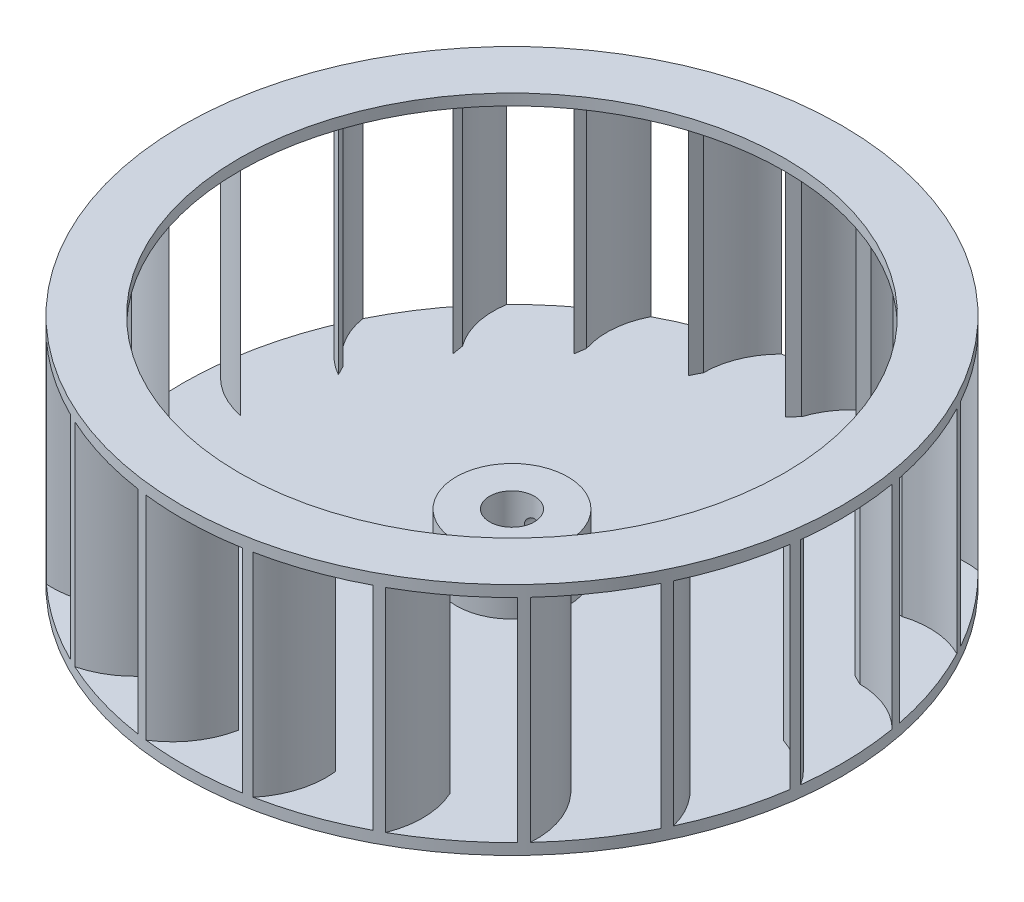
from build123d import *

# Parameters (mm, degrees)
SKETCH2_R           = 59
BOSS_EXTRUDE1_DEPTH = 2
BOSS_EXTRUDE2_DEPTH = 38
SKETCH4_R           = 59
SKETCH4_R_2         = 48.802353881
BOSS_EXTRUDE3_DEPTH = 2
SKETCH5_R           = 10
SKETCH5_R_2         = 4
BOSS_EXTRUDE4_DEPTH = 10
SKETCH6_R           = 1.5
CUT_EXTRUDE1_DEPTH  = 25
SKETCH7_R           = 4
CUT_EXTRUDE2_DEPTH  = 3


with BuildPart() as part:
    # Sketch2 → Boss-Extrude1 (new body)
    with BuildSketch(Plane(origin=(0, 0, 0), x_dir=(1, 0, 0), z_dir=(0, 1, 0))):
        Circle(SKETCH2_R)
    extrude(amount=BOSS_EXTRUDE1_DEPTH)

    # Sketch3 → Boss-Extrude2 (add)
    with BuildSketch(Plane(origin=(0, 2, 0), x_dir=(1, 0, 0), z_dir=(0, 1, 0))):
        with BuildLine():
            Line((-14.892857143, 46.474428995), (-14, 48.26406754))
            ThreePointArc((-14, 48.26406754), (-12.934313455, 53.621635593), (-9.899494937, 58.163562477))
            ThreePointArc((-9.899494937, 58.163562477), (-10.714001991, 58.019049986), (-11.526402854, 57.863131934))
            ThreePointArc((-11.526402854, 57.863131934), (-14.384712835, 52.516130174), (-14.892857143, 46.474428995))
        make_face()
        with BuildLine():
            Line((0.197439531, 48.801954489), (1.599625859, 50.228093858))
            ThreePointArc((1.599625859, 50.228093858), (4.268733569, 54.994128614), (8.558550091, 58.375947276))
            ThreePointArc((8.558550091, 58.375947276), (7.739251034, 58.490204252), (6.918430571, 58.592963045))
            ThreePointArc((6.918430571, 58.592963045), (2.547701825, 54.390928538), (0.197439531, 48.801954489))
        make_face()
        with BuildLine():
            Line((15.268409449, 46.352404654), (17.042669195, 47.27544439))
            ThreePointArc((17.042669195, 47.27544439), (21.05392721, 50.983413159), (26.178824605, 52.874087626))
            ThreePointArc((26.178824605, 52.874087626), (25.434932246, 53.2359298), (24.686039809, 53.587306692))
            ThreePointArc((24.686039809, 53.587306692), (19.230729681, 50.941563853), (15.268409449, 46.352404654))
        make_face()
        with BuildLine():
            Line((28.844801068, 39.365558495), (30.817457326, 39.695145037))
            ThreePointArc((30.817457326, 39.695145037), (35.778215764, 41.982086001), (41.236533368, 42.196543884))
            ThreePointArc((41.236533368, 42.196543884), (40.640865073, 42.770551623), (40.037207473, 43.336151396))
            ThreePointArc((40.037207473, 43.336151396), (34.031319726, 42.505683967), (28.844801068, 39.365558495))
        make_face()
        with BuildLine():
            Line((39.597662585, 28.525337195), (41.575618016, 28.229208316))
            ThreePointArc((41.575618016, 28.229208316), (47.000283277, 28.87125976), (52.257722933, 27.388508426))
            ThreePointArc((52.257722933, 27.388508426), (51.868586866, 28.118493853), (51.469254313, 28.842951659))
            ThreePointArc((51.469254313, 28.842951659), (45.500687087, 29.90905158), (39.597662585, 28.525337195))
        make_face()
        with BuildLine():
            Line((46.474428995, 14.892857143), (48.26406754, 14))
            ThreePointArc((48.26406754, 14), (53.621635593, 12.934313455), (58.163562477, 9.899494937))
            ThreePointArc((58.163562477, 9.899494937), (58.019049986, 10.714001991), (57.863131934, 11.526402854))
            ThreePointArc((57.863131934, 11.526402854), (52.516130174, 14.384712835), (46.474428995, 14.892857143))
        make_face()
        with BuildLine():
            Line((48.801954489, -0.197439531), (50.228093858, -1.599625859))
            ThreePointArc((50.228093858, -1.599625859), (54.994128614, -4.268733569), (58.375947276, -8.558550091))
            ThreePointArc((58.375947276, -8.558550091), (58.490204252, -7.739251034), (58.592963045, -6.918430571))
            ThreePointArc((58.592963045, -6.918430571), (54.390928538, -2.547701825), (48.801954489, -0.197439531))
        make_face()
        with BuildLine():
            Line((46.352404654, -15.268409449), (47.27544439, -17.042669195))
            ThreePointArc((47.27544439, -17.042669195), (50.983413159, -21.05392721), (52.874087626, -26.178824605))
            ThreePointArc((52.874087626, -26.178824605), (53.2359298, -25.434932246), (53.587306692, -24.686039809))
            ThreePointArc((53.587306692, -24.686039809), (50.941563853, -19.230729681), (46.352404654, -15.268409449))
        make_face()
        with BuildLine():
            Line((39.365558495, -28.844801068), (39.695145037, -30.817457326))
            ThreePointArc((39.695145037, -30.817457326), (41.982086001, -35.778215764), (42.196543884, -41.236533368))
            ThreePointArc((42.196543884, -41.236533368), (42.770551623, -40.640865073), (43.336151396, -40.037207473))
            ThreePointArc((43.336151396, -40.037207473), (42.505683967, -34.031319726), (39.365558495, -28.844801068))
        make_face()
        with BuildLine():
            Line((28.525337195, -39.597662585), (28.229208316, -41.575618016))
            ThreePointArc((28.229208316, -41.575618016), (28.87125976, -47.000283277), (27.388508426, -52.257722933))
            ThreePointArc((27.388508426, -52.257722933), (28.118493853, -51.868586866), (28.842951659, -51.469254313))
            ThreePointArc((28.842951659, -51.469254313), (29.90905158, -45.500687087), (28.525337195, -39.597662585))
        make_face()
        with BuildLine():
            Line((14.892857143, -46.474428995), (14, -48.26406754))
            ThreePointArc((14, -48.26406754), (12.934313455, -53.621635593), (9.899494937, -58.163562477))
            ThreePointArc((9.899494937, -58.163562477), (10.714001991, -58.019049986), (11.526402854, -57.863131934))
            ThreePointArc((11.526402854, -57.863131934), (14.384712835, -52.516130174), (14.892857143, -46.474428995))
        make_face()
        with BuildLine():
            Line((-0.197439531, -48.801954489), (-1.599625859, -50.228093858))
            ThreePointArc((-1.599625859, -50.228093858), (-4.268733569, -54.994128614), (-8.558550091, -58.375947276))
            ThreePointArc((-8.558550091, -58.375947276), (-7.739251034, -58.490204252), (-6.918430571, -58.592963045))
            ThreePointArc((-6.918430571, -58.592963045), (-2.547701825, -54.390928538), (-0.197439531, -48.801954489))
        make_face()
        with BuildLine():
            Line((-15.268409449, -46.352404654), (-17.042669195, -47.27544439))
            ThreePointArc((-17.042669195, -47.27544439), (-21.05392721, -50.983413159), (-26.178824605, -52.874087626))
            ThreePointArc((-26.178824605, -52.874087626), (-25.434932246, -53.2359298), (-24.686039809, -53.587306692))
            ThreePointArc((-24.686039809, -53.587306692), (-19.230729681, -50.941563853), (-15.268409449, -46.352404654))
        make_face()
        with BuildLine():
            Line((-28.844801068, -39.365558495), (-30.817457326, -39.695145037))
            ThreePointArc((-30.817457326, -39.695145037), (-35.778215764, -41.982086001), (-41.236533368, -42.196543884))
            ThreePointArc((-41.236533368, -42.196543884), (-40.640865073, -42.770551623), (-40.037207473, -43.336151396))
            ThreePointArc((-40.037207473, -43.336151396), (-34.031319726, -42.505683967), (-28.844801068, -39.365558495))
        make_face()
        with BuildLine():
            Line((-39.597662585, -28.525337195), (-41.575618016, -28.229208316))
            ThreePointArc((-41.575618016, -28.229208316), (-47.000283277, -28.87125976), (-52.257722933, -27.388508426))
            ThreePointArc((-52.257722933, -27.388508426), (-51.868586866, -28.118493853), (-51.469254313, -28.842951659))
            ThreePointArc((-51.469254313, -28.842951659), (-45.500687087, -29.90905158), (-39.597662585, -28.525337195))
        make_face()
        with BuildLine():
            Line((-46.474428995, -14.892857143), (-48.26406754, -14))
            ThreePointArc((-48.26406754, -14), (-53.621635593, -12.934313455), (-58.163562477, -9.899494937))
            ThreePointArc((-58.163562477, -9.899494937), (-58.019049986, -10.714001991), (-57.863131934, -11.526402854))
            ThreePointArc((-57.863131934, -11.526402854), (-52.516130174, -14.384712835), (-46.474428995, -14.892857143))
        make_face()
        with BuildLine():
            Line((-48.801954489, 0.197439531), (-50.228093858, 1.599625859))
            ThreePointArc((-50.228093858, 1.599625859), (-54.994128614, 4.268733569), (-58.375947276, 8.558550091))
            ThreePointArc((-58.375947276, 8.558550091), (-58.490204252, 7.739251034), (-58.592963045, 6.918430571))
            ThreePointArc((-58.592963045, 6.918430571), (-54.390928538, 2.547701825), (-48.801954489, 0.197439531))
        make_face()
        with BuildLine():
            Line((-46.352404654, 15.268409449), (-47.27544439, 17.042669195))
            ThreePointArc((-47.27544439, 17.042669195), (-50.983413159, 21.05392721), (-52.874087626, 26.178824605))
            ThreePointArc((-52.874087626, 26.178824605), (-53.2359298, 25.434932246), (-53.587306692, 24.686039809))
            ThreePointArc((-53.587306692, 24.686039809), (-50.941563853, 19.230729681), (-46.352404654, 15.268409449))
        make_face()
        with BuildLine():
            Line((-39.365558495, 28.844801068), (-39.695145037, 30.817457326))
            ThreePointArc((-39.695145037, 30.817457326), (-41.982086001, 35.778215764), (-42.196543884, 41.236533368))
            ThreePointArc((-42.196543884, 41.236533368), (-42.770551623, 40.640865073), (-43.336151396, 40.037207473))
            ThreePointArc((-43.336151396, 40.037207473), (-42.505683967, 34.031319726), (-39.365558495, 28.844801068))
        make_face()
        with BuildLine():
            Line((-28.525337195, 39.597662585), (-28.229208316, 41.575618016))
            ThreePointArc((-28.229208316, 41.575618016), (-28.87125976, 47.000283277), (-27.388508426, 52.257722933))
            ThreePointArc((-27.388508426, 52.257722933), (-28.118493853, 51.868586866), (-28.842951659, 51.469254313))
            ThreePointArc((-28.842951659, 51.469254313), (-29.90905158, 45.500687087), (-28.525337195, 39.597662585))
        make_face()
    extrude(amount=BOSS_EXTRUDE2_DEPTH)

    # Sketch4 → Boss-Extrude3 (add)
    with BuildSketch(Plane(origin=(0, 40, 0), x_dir=(1, 0, 0), z_dir=(0, 1, 0))):
        Circle(SKETCH4_R)
        Circle(SKETCH4_R_2, mode=Mode.SUBTRACT)
    extrude(amount=BOSS_EXTRUDE3_DEPTH)

    # Sketch5 → Boss-Extrude4 (add)
    with BuildSketch(Plane(origin=(0, 2, 0), x_dir=(1, 0, 0), z_dir=(0, 1, 0))):
        Circle(SKETCH5_R)
        Circle(SKETCH5_R_2, mode=Mode.SUBTRACT)
    extrude(amount=BOSS_EXTRUDE4_DEPTH)

    # Sketch6 → Cut-Extrude1 (cut)
    with BuildSketch(Plane.XY):
        with Locations((0, 7)):
            Circle(SKETCH6_R)
    extrude(amount=-CUT_EXTRUDE1_DEPTH, mode=Mode.SUBTRACT)

    # Sketch7 → Cut-Extrude2 (cut, through all)
    with BuildSketch(Plane(origin=(0, 2, 0), x_dir=(1, 0, 0), z_dir=(0, 1, 0))):
        Circle(SKETCH7_R)
    extrude(amount=-CUT_EXTRUDE2_DEPTH, mode=Mode.SUBTRACT)


solid = part.part
